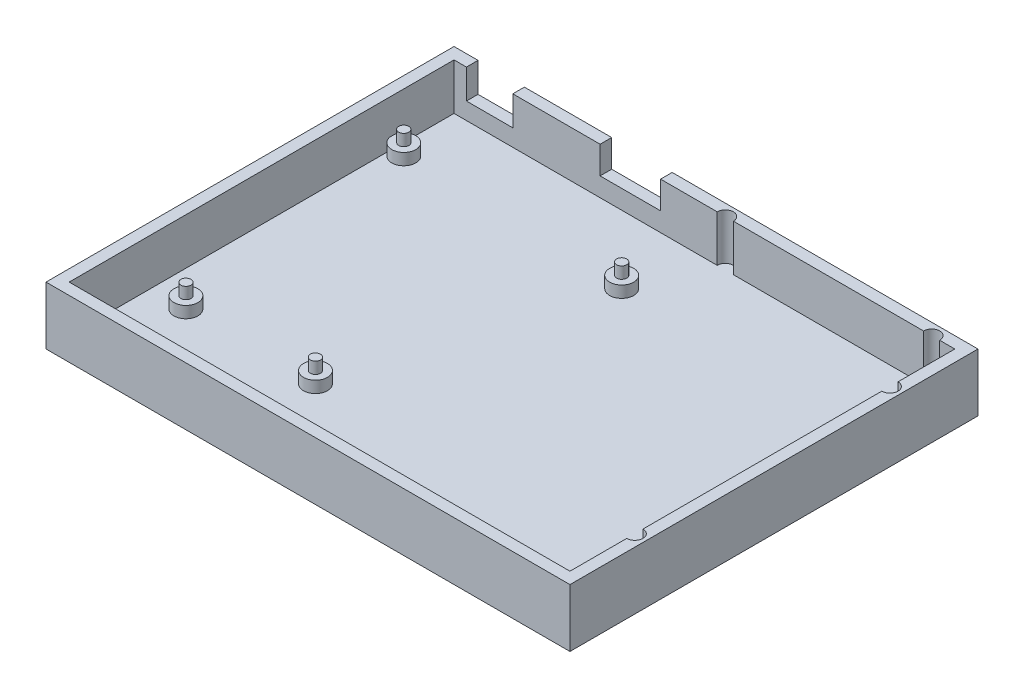
from build123d import *

# Parameters (mm, degrees)
SKETCH1_W           = 113
SKETCH1_H           = 88
BOSS_EXTRUDE1_DEPTH = 2.5
SKETCH1_3_W         = 113
SKETCH1_3_H         = 88
SKETCH1_3_W_2       = 108
SKETCH1_3_H_2       = 83
BOSS_EXTRUDE2_DEPTH = 12.5
CUT_EXTRUDE4_REACH  = 90
SKETCH2_W           = 13.04
SKETCH2_H           = 5.92
SKETCH2_W_2         = 10
SKETCH2_H_2         = 6.35
SKETCH4_R           = 2.5875
BOSS_EXTRUDE5_DEPTH = 2.5
SKETCH4_4_R         = 1.0875
BOSS_EXTRUDE6_DEPTH = 5
CUT_EXTRUDE5_START  = -10
CUT_EXTRUDE5_DEPTH  = 10


with BuildPart() as part:
    # Sketch1 → Boss-Extrude1 (new body)
    with BuildSketch(Plane(origin=(0, 0, 0), x_dir=(1, 0, 0), z_dir=(0, 1, 0))):
        with Locations((54, 41.5)):
            Rectangle(SKETCH1_W, SKETCH1_H)
    extrude(amount=BOSS_EXTRUDE1_DEPTH)

    # Sketch1_3 → Boss-Extrude2 (add)
    with BuildSketch(Plane(origin=(0, 0, 0), x_dir=(1, 0, 0), z_dir=(0, 1, 0))):
        with Locations((54, 41.5)):
            Rectangle(SKETCH1_3_W, SKETCH1_3_H)
        with Locations((54, 41.5)):
            Rectangle(SKETCH1_3_W_2, SKETCH1_3_H_2, mode=Mode.SUBTRACT)
    extrude(amount=BOSS_EXTRUDE2_DEPTH)

    # Sketch2 → Cut-Extrude4 (cut, up to next)
    with BuildSketch(Plane(origin=(0, 0, -85.5), x_dir=(-1, 0, 0), z_dir=(0, 0, -1)), mode=Mode.PRIVATE) as cut_extrude4_sk1:
        with Locations((-38.02, 9.54)):
            Rectangle(SKETCH2_W, SKETCH2_H)
    cut_extrude4_tool1 = extrude(cut_extrude4_sk1.sketch, amount=-CUT_EXTRUDE4_REACH, mode=Mode.PRIVATE) & part.part
    add(cut_extrude4_tool1.solids().sort_by_distance((38.02, 9.54, -85.5))[0], mode=Mode.SUBTRACT)
    # Sketch2 → Cut-Extrude4 (cut, up to next)
    with BuildSketch(Plane(origin=(0, 0, -85.5), x_dir=(-1, 0, 0), z_dir=(0, 0, -1)), mode=Mode.PRIVATE) as cut_extrude4_sk2:
        with Locations((-7.675, 9.325)):
            Rectangle(SKETCH2_W_2, SKETCH2_H_2)
    cut_extrude4_tool2 = extrude(cut_extrude4_sk2.sketch, amount=-CUT_EXTRUDE4_REACH, mode=Mode.PRIVATE) & part.part
    add(cut_extrude4_tool2.solids().sort_by_distance((7.675, 9.325, -85.5))[0], mode=Mode.SUBTRACT)

    # Sketch4 → Boss-Extrude5 (add)
    with BuildSketch(Plane(origin=(0, 2.5, 0), x_dir=(1, 0, 0), z_dir=(0, 1, 0))):
        with Locations((2.54, 69.625)):
            Circle(SKETCH4_R)
        with Locations((50.8, 68.355)):
            Circle(SKETCH4_R)
        with Locations((7.62, 17.555)):
            Circle(SKETCH4_R)
        with Locations((35.56, 17.555)):
            Circle(SKETCH4_R)
    extrude(amount=BOSS_EXTRUDE5_DEPTH)

    # Sketch4_4 → Boss-Extrude6 (add)
    with BuildSketch(Plane(origin=(0, 2.5, 0), x_dir=(1, 0, 0), z_dir=(0, 1, 0))):
        with Locations((2.54, 69.625)):
            Circle(SKETCH4_4_R)
        with Locations((50.8, 68.355)):
            Circle(SKETCH4_4_R)
        with Locations((7.62, 17.555)):
            Circle(SKETCH4_4_R)
        with Locations((35.56, 17.555)):
            Circle(SKETCH4_4_R)
    extrude(amount=BOSS_EXTRUDE6_DEPTH)

    # Sketch5 → Cut-Extrude5 (cut)
    with BuildSketch(Plane(origin=(0, 12.5, 0), x_dir=(1, 0, 0), z_dir=(0, 1, 0)).offset(CUT_EXTRUDE5_START)):
        with BuildLine():
            Line((101.25, 83), (104.75, 83))
            ThreePointArc((104.75, 83), (103, 84.75), (101.25, 83))
        make_face()
        with BuildLine():
            Line((56.75, 83), (60.25, 83))
            ThreePointArc((60.25, 83), (58.5, 84.75), (56.75, 83))
        make_face()
        with BuildLine():
            Line((108, 70.75), (108, 67.25))
            ThreePointArc((108, 67.25), (109.75, 69), (108, 70.75))
        make_face()
        with BuildLine():
            Line((108, 15.75), (108, 12.25))
            ThreePointArc((108, 12.25), (109.75, 14), (108, 15.75))
        make_face()
    extrude(amount=CUT_EXTRUDE5_DEPTH, mode=Mode.SUBTRACT)


solid = part.part
